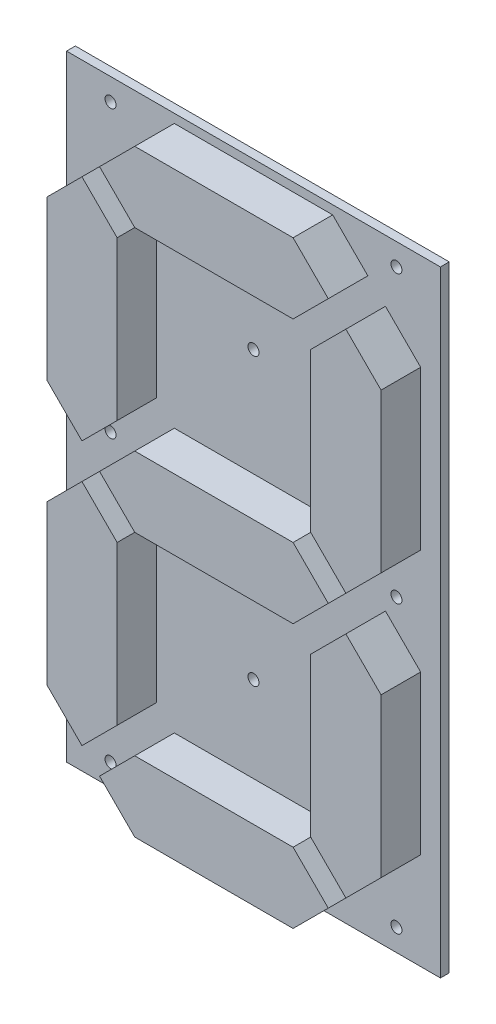
from build123d import *

# Parameters (mm, degrees)
CROQUIS1_W              = 85
CROQUIS1_H              = 140
CROQUIS1_R              = 1.25
SALIENTE_EXTRUIR1_DEPTH = 2
SALIENTE_EXTRUIR2_DEPTH = 9


with BuildPart() as part:
    # Croquis1 → Saliente-Extruir1 (new body)
    with BuildSketch(Plane.XY):
        Rectangle(CROQUIS1_W, CROQUIS1_H)
        with Locations((-32.5, 65)):
            Circle(CROQUIS1_R, mode=Mode.SUBTRACT)
        with Locations((32.5, 65)):
            Circle(CROQUIS1_R, mode=Mode.SUBTRACT)
        with Locations((-32.5, 0)):
            Circle(CROQUIS1_R, mode=Mode.SUBTRACT)
        with Locations((32.5, 0)):
            Circle(CROQUIS1_R, mode=Mode.SUBTRACT)
        with Locations((-32.5, -65)):
            Circle(CROQUIS1_R, mode=Mode.SUBTRACT)
        with Locations((32.5, -65)):
            Circle(CROQUIS1_R, mode=Mode.SUBTRACT)
        with Locations((0, -32.5)):
            Circle(CROQUIS1_R, mode=Mode.SUBTRACT)
        with Locations((0, 32.5)):
            Circle(CROQUIS1_R, mode=Mode.SUBTRACT)
    extrude(amount=SALIENTE_EXTRUIR1_DEPTH)

    # Croquis2 → Saliente-Extruir2 (add)
    with BuildSketch(Plane.XY.offset(2)):
        Polygon((22, 48), (30, 56), (38, 48), (38, 12), (30, 4), (22, 12), align=None)
        Polygon((-22, 48), (-30, 56), (-38, 48), (-38, 12), (-30, 4), (-22, 12), align=None)
        Polygon((22, -48), (30, -56), (38, -48), (38, -12), (30, -4), (22, -12), align=None)
        Polygon((-22, -48), (-30, -56), (-38, -48), (-38, -12), (-30, -4), (-22, -12), align=None)
        Polygon((-18, -8), (-26, 0), (-18, 8), (18, 8), (26, 0), (18, -8), align=None)
        Polygon((-18.000001585, 52.000001585), (-26.000001585, 60.000001585), (-18.000001585, 68.000001585), (17.999998415, 68.000001585), (25.999998415, 60.000001585), (17.999998415, 52.000001585), align=None)
        Polygon((-18.000001585, -52.000001585), (-26.000001585, -60.000001585), (-18.000001585, -68.000001585), (17.999998415, -68.000001585), (25.999998415, -60.000001585), (17.999998415, -52.000001585), align=None)
    extrude(amount=SALIENTE_EXTRUIR2_DEPTH)


solid = part.part
